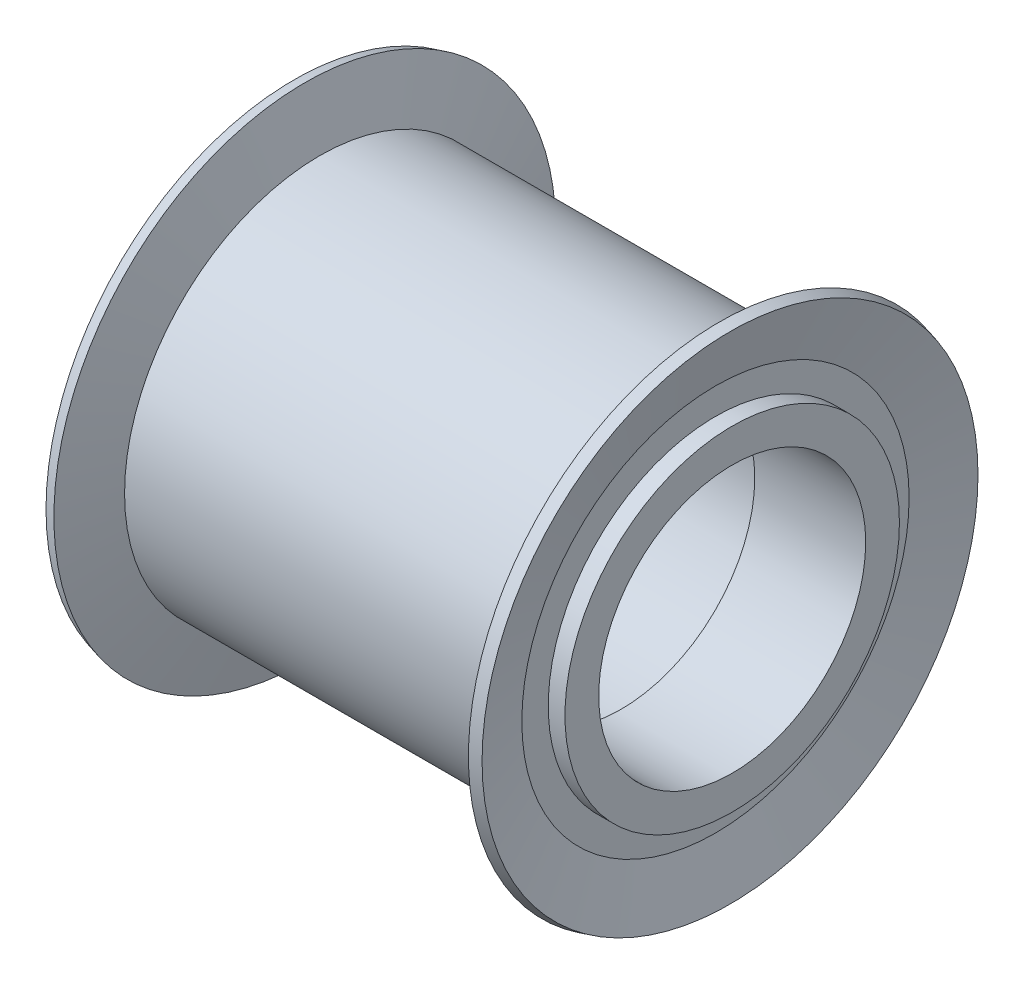
from build123d import *


with BuildPart() as part:
    # Sketch1 → Revolve1 (revolve)
    with BuildSketch(Plane.XY):
        Polygon((-4.130434783, 6.52173913), (-4.782608696, 6.52173913), (-4.782608696, 5.652173913), (3.544347826, 5.652173913), (3.544347826, 5.913043478), (4.064347826, 5.913043478), (4.064347826, 5.652173913), (8.064347826, 5.652173913), (8.064347826, 5.206608489), (12.391304348, 5.206608489), (12.391304348, 6.52173913), (11.739130435, 6.52173913), (11.739130435, 7.551455436), (12.306813821, 9.670078676), (11.886846071, 9.782608696), (11.304347826, 7.608695652), (-3.695652174, 7.608695652), (-4.278150418, 9.782608696), (-4.698118169, 9.670078676), (-4.130434783, 7.551455436), align=None)
    revolve(axis=Axis((-4.784782609, 0, 0), (1, 0, 0)))


solid = part.part
